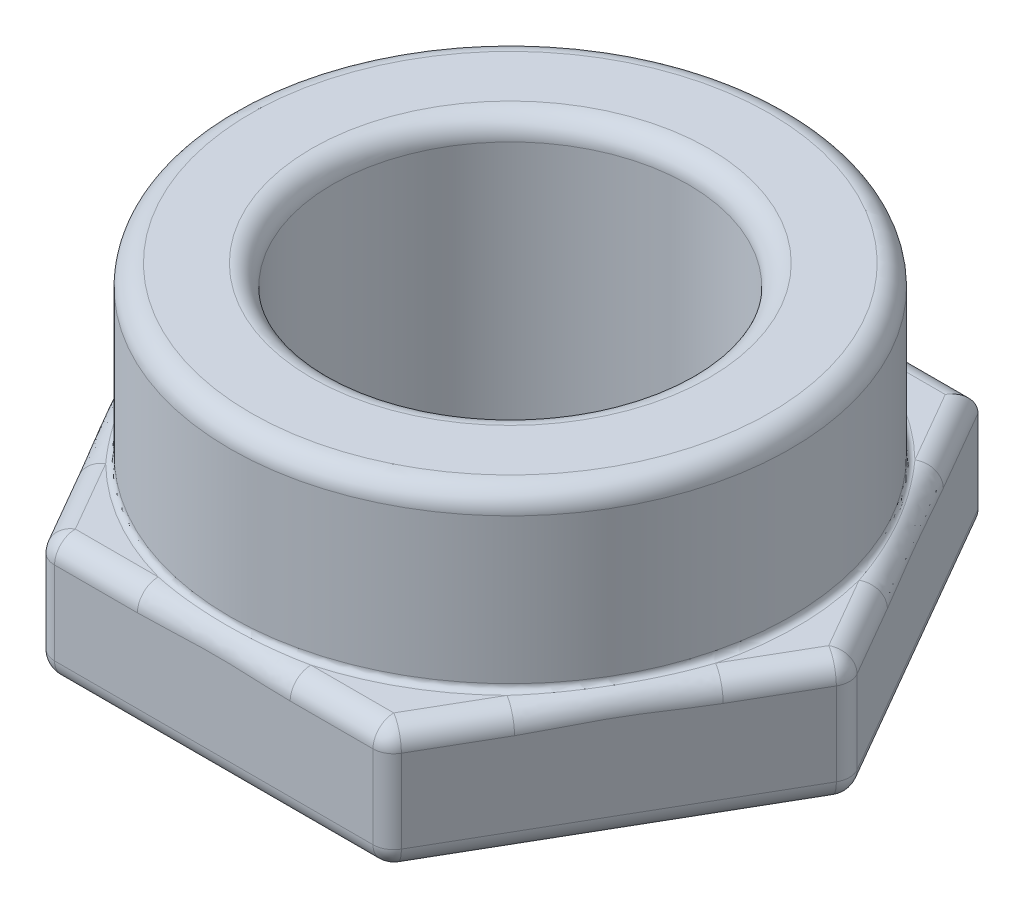
from build123d import *

# Parameters (mm, degrees)
BOSS_EXTRUDE1_DEPTH = 10.668
SKETCH2_R           = 24.003
BOSS_EXTRUDE2_DEPTH = 14.732
SKETCH3_R           = 15.24
CUT_EXTRUDE1_DEPTH  = 26.4
FILLET2_R           = 0.508
FILLET1_R           = 1.778


with BuildPart() as part:
    # Sketch1 → Boss-Extrude1 (new body)
    with BuildSketch(Plane(origin=(0, 0, 0), x_dir=(1, 0, 0), z_dir=(0, 1, 0))):
        Polygon((29.329393675, 0), (14.664696837, 25.4), (-14.664696837, 25.4), (-29.329393675, 0), (-14.664696837, -25.4), (14.664696837, -25.4), align=None)
    extrude(amount=BOSS_EXTRUDE1_DEPTH)

    # Sketch2 → Boss-Extrude2 (add)
    with BuildSketch(Plane(origin=(0, 10.668, 0), x_dir=(1, 0, 0), z_dir=(0, 1, 0))):
        Circle(SKETCH2_R)
    extrude(amount=BOSS_EXTRUDE2_DEPTH)

    # Sketch3 → Cut-Extrude1 (cut, through all)
    with BuildSketch(Plane(origin=(0, 25.4, 0), x_dir=(1, 0, 0), z_dir=(0, 1, 0))):
        Circle(SKETCH3_R)
    extrude(amount=-CUT_EXTRUDE1_DEPTH, mode=Mode.SUBTRACT)

    # Fillet2
    fillet2_edges = [part.edges().sort_by_distance(p)[0] for p in [
        (-24.003, 10.668, 0),
    ]]
    fillet(fillet2_edges, radius=FILLET2_R)

    # Fillet1
    fillet1_edges = [part.edges().sort_by_distance(p)[0] for p in [
        (0, 10.668, -25.4),
        (14.664696837, 5.334, 25.4),
        (-14.664696837, 5.334, 25.4),
        (-29.329393675, 5.334, 0),
        (-14.664696837, 5.334, -25.4),
        (29.329393675, 5.334, 0),
        (-21.997045256, 10.668, -12.7),
        (-21.997045256, 10.668, 12.7),
        (0, 10.668, 25.4),
        (-24.003, 25.4, 0),
        (-15.24, 0, 0),
        (-15.24, 25.4, 0),
        (21.997045256, 10.668, 12.7),
        (0, 0, 25.4),
        (-21.997045256, 0, 12.7),
        (-21.997045256, 0, -12.7),
        (21.997045256, 10.668, -12.7),
        (0, 0, -25.4),
        (21.997045256, 0, -12.7),
        (21.997045256, 0, 12.7),
    ]]
    fillet(fillet1_edges, radius=FILLET1_R)


solid = part.part
